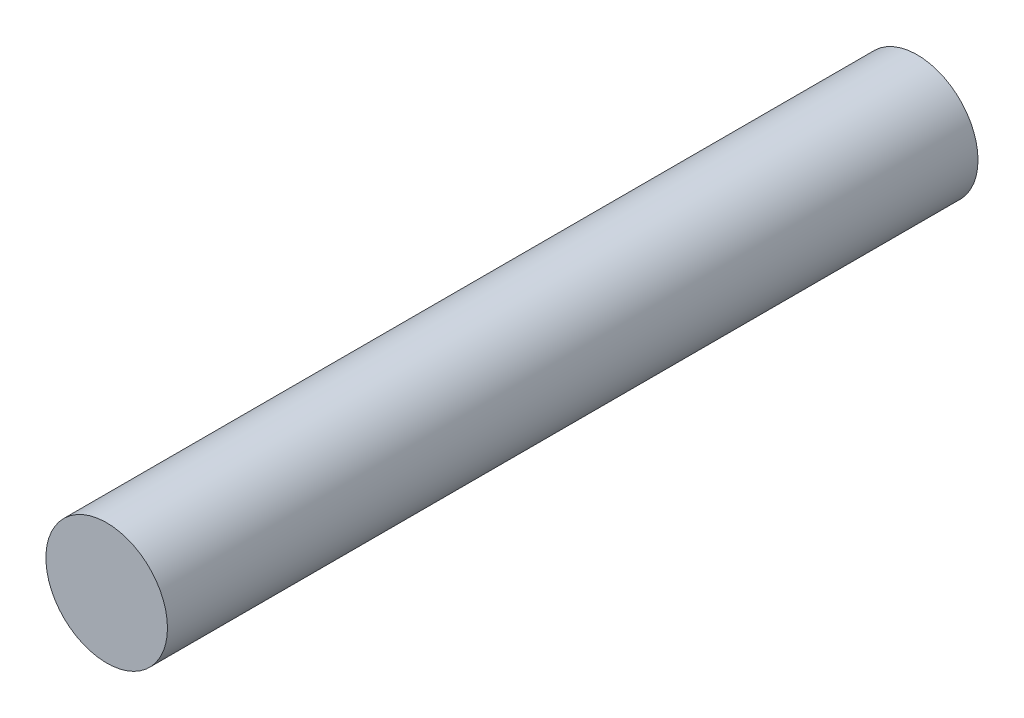
from build123d import *

# Parameters (mm, degrees)
ESQUISSE1_W = 1.5
ESQUISSE1_H = 20


with BuildPart() as part:
    # Esquisse1 → Révolution1 (revolve)
    with BuildSketch(Plane(origin=(0, 0, 0), x_dir=(1, 0, 0), z_dir=(0, 1, 0))):
        with Locations((0.75, -10)):
            Rectangle(ESQUISSE1_W, ESQUISSE1_H)
    revolve(axis=Axis((0, 0, 0), (0, 0, 1)))


solid = part.part
